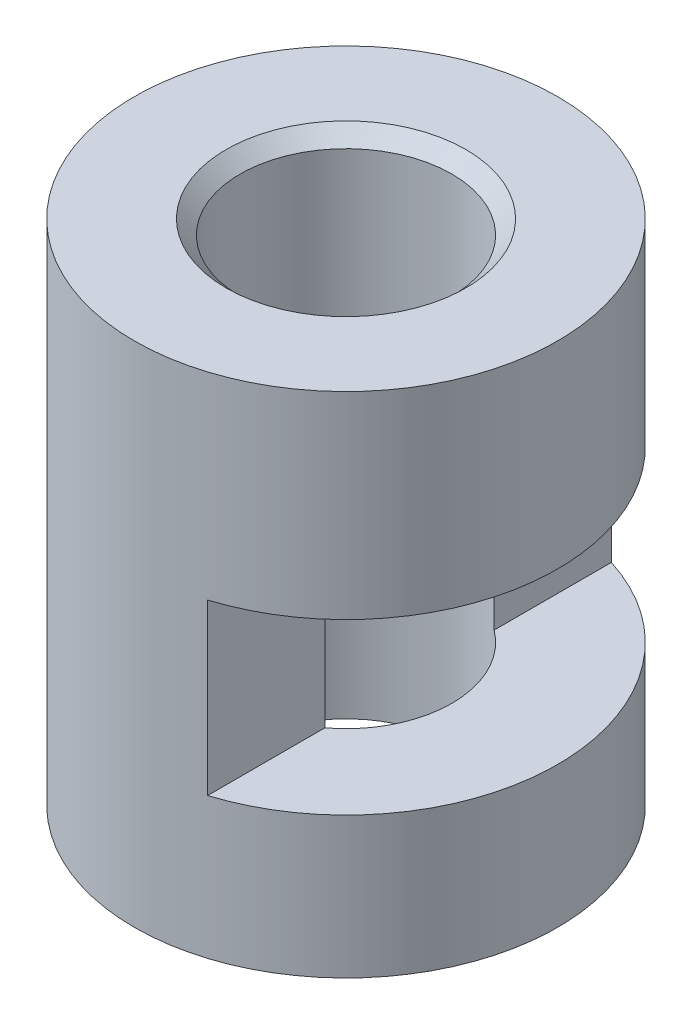
from build123d import *

# Parameters (mm, degrees)
SKETCH1_R               = 3
BOSS_EXTRUDE1_DEPTH     = 7.2
CUT_EXTRUDE1_REACH      = 9.2
SKETCH2_R               = 1.5
SKETCH3_W               = 2.1
SKETCH3_H               = 2.4
CUT_EXTRUDE2_DEPTH      = 4
CUT_EXTRUDE2_DEPTH_BACK = 4
CHAMFER1_SIZE           = 0.2


with BuildPart() as part:
    # Sketch1 → Boss-Extrude1 (new body)
    with BuildSketch(Plane(origin=(0, 0, 0), x_dir=(1, 0, 0), z_dir=(0, 1, 0))):
        Circle(SKETCH1_R)
    extrude(amount=BOSS_EXTRUDE1_DEPTH)

    # Sketch2 → Cut-Extrude1 (cut, up to next)
    with BuildSketch(Plane(origin=(0, 7.2, 0), x_dir=(1, 0, 0), z_dir=(0, 1, 0)), mode=Mode.PRIVATE) as cut_extrude1_sk1:
        Circle(SKETCH2_R)
    cut_extrude1_tool1 = extrude(cut_extrude1_sk1.sketch, amount=-CUT_EXTRUDE1_REACH, mode=Mode.PRIVATE) & part.part
    add(cut_extrude1_tool1.solids().sort_by_distance((0, 7.2, 0))[0], mode=Mode.SUBTRACT)

    # Sketch3 → Cut-Extrude2 (cut, two sides)
    with BuildSketch(Plane.XY) as cut_extrude2_sk:
        with Locations((1.95, 3.2)):
            Rectangle(SKETCH3_W, SKETCH3_H)
    extrude(amount=CUT_EXTRUDE2_DEPTH, mode=Mode.SUBTRACT)
    extrude(cut_extrude2_sk.sketch, amount=-CUT_EXTRUDE2_DEPTH_BACK, mode=Mode.SUBTRACT)

    # Chamfer1
    chamfer1_edges = [part.edges().sort_by_distance(p)[0] for p in [
        (-1.5, 7.2, 0),
    ]]
    chamfer(chamfer1_edges, length=CHAMFER1_SIZE)


solid = part.part
